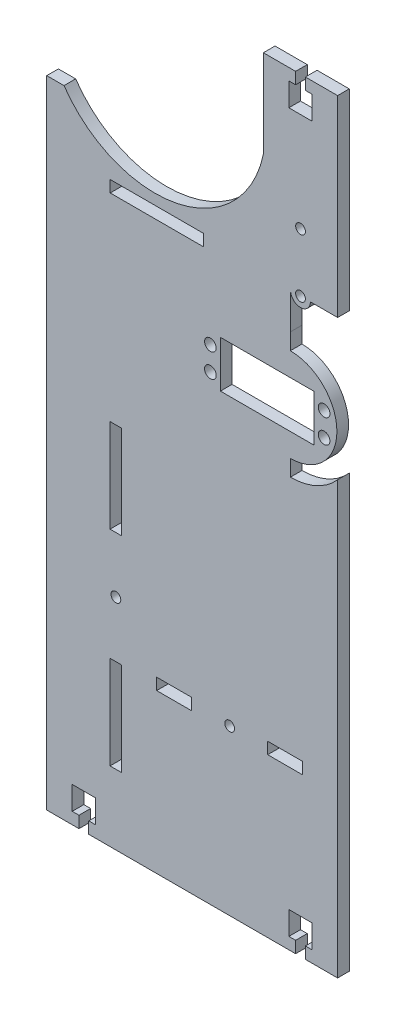
from build123d import *

# Parameters (mm, degrees)
SKETCH1_W           = 31.86
SKETCH1_H           = 328
BOSS_EXTRUDE1_DEPTH = 5
SKETCH2_R           = 2.1
CUT_EXTRUDE1_DEPTH  = 10
CUT_EXTRUDE2_DEPTH  = 10
BOSS_EXTRUDE2_DEPTH = 5
SKETCH7_W           = 4.2
SKETCH7_H           = 5
SKETCH7_R           = 2.099999245
CUT_EXTRUDE3_DEPTH  = 5
SKETCH8_R           = 2.499996422
SKETCH8_R_2         = 2.499996502
SKETCH8_R_3         = 2.5
SKETCH8_W           = 40.200355047
SKETCH8_H           = 20
CUT_EXTRUDE4_DEPTH  = 10
CUT_EXTRUDE5_DEPTH  = 10
CUT_EXTRUDE6_DEPTH  = 10
SKETCH12_R          = 2.100000755
SKETCH12_R_2        = 2.1
SKETCH12_W          = 15.000005391
SKETCH12_H          = 5
SKETCH12_W_2        = 5
SKETCH12_H_2        = 40
CUT_EXTRUDE7_DEPTH  = 5
SKETCH15_W          = 40
SKETCH15_H          = 5
CUT_EXTRUDE8_DEPTH  = 5


with BuildPart() as part:
    # Sketch1 → Boss-Extrude1 (new body)
    with BuildSketch(Plane.XY):
        Rectangle(SKETCH1_W, SKETCH1_H)
    extrude(amount=BOSS_EXTRUDE1_DEPTH)

    # Sketch2 → Cut-Extrude1 (cut)
    with BuildSketch(Plane.XY.offset(5)):
        with Locations((0, 81.5)):
            Circle(SKETCH2_R)
    extrude(amount=-CUT_EXTRUDE1_DEPTH, mode=Mode.SUBTRACT)

    # Sketch3 → Cut-Extrude2 (cut)
    with BuildSketch(Plane.XY.offset(5)):
        Polygon((2.1, 164), (2.1, 159), (5, 159), (5, 149), (-5, 149), (-5, 159), (-2.1, 159), (-2.1, 164), align=None)
        Polygon((-2.1, -164), (-2.1, -159), (-5, -159), (-5, -149), (5, -149), (5, -159), (2.1, -159), (2.1, -164), align=None)
    extrude(amount=-CUT_EXTRUDE2_DEPTH, mode=Mode.SUBTRACT)

    # Sketch4 → Boss-Extrude2 (add)
    with BuildSketch(Plane(origin=(0, 0, 0), x_dir=(-1, 0, 0), z_dir=(0, 0, -1))):
        with BuildLine():
            Line((15.93, -164), (108.913444487, -164))
            Line((108.913444487, -164), (108.913444487, 109))
            Line((108.913444487, 109), (101.503490547, 109))
            ThreePointArc((101.503490547, 109), (62.423444487, 88.5), (23.343398428, 109))
            ThreePointArc((23.343398428, 109), (18.773737927, 117.266257257), (15.93, 126.273252357))
            Line((15.93, 126.273252357), (15.93, 109))
            Line((15.93, 109), (15.93, -164))
        make_face()
    extrude(amount=-BOSS_EXTRUDE2_DEPTH)

    # Sketch7 → Cut-Extrude3 (cut)
    with BuildSketch(Plane.XY.offset(5)):
        Polygon((-95.083444487, -159), (-90.883444487, -159), (-87.983444487, -159), (-87.983444487, -149), (-97.983444487, -149), (-97.983444487, -159), align=None)
        with Locations((-92.983444487, -161.5)):
            Rectangle(SKETCH7_W, SKETCH7_H)
        with Locations((0.021526005, 106.5)):
            Circle(SKETCH7_R)
    extrude(amount=-CUT_EXTRUDE3_DEPTH, mode=Mode.SUBTRACT)

    # Sketch8 → Cut-Extrude4 (cut)
    with BuildSketch(Plane.XY.offset(5)):
        with Locations((-38.679067758, 44.08)):
            Circle(SKETCH8_R)
        with Locations((-38.679067758, 33.92)):
            Circle(SKETCH8_R_2)
        with Locations((10.13, 44.08)):
            Circle(SKETCH8_R_3)
        with Locations((10.13, 33.92)):
            Circle(SKETCH8_R_3)
        with Locations((-14.269822477, 39)):
            Rectangle(SKETCH8_W, SKETCH8_H)
    extrude(amount=-CUT_EXTRUDE4_DEPTH, mode=Mode.SUBTRACT)

    # Sketch9 → Cut-Extrude5 (cut)
    with BuildSketch(Plane(origin=(0, 0, 0), x_dir=(-1, 0, 0), z_dir=(0, 0, -1))):
        with BuildLine():
            Line((4.37, 12), (4.37, 19))
            ThreePointArc((4.37, 19), (-15.63, 39), (4.37, 59))
            Line((4.37, 59), (4.37, 66))
            ThreePointArc((4.37, 66), (-22.63, 39), (4.37, 12))
        make_face()
    extrude(amount=-CUT_EXTRUDE5_DEPTH, mode=Mode.SUBTRACT)

    # Sketch10 → Cut-Extrude6 (cut)
    with BuildSketch(Plane(origin=(0, 0, 0), x_dir=(-1, 0, 0), z_dir=(0, 0, -1))):
        with BuildLine():
            Line((-15.93, 66), (-15.93, 56.801966184))
            ThreePointArc((-15.93, 56.801966184), (-6.773314432, 63.593221495), (4.37, 66))
            Line((4.37, 66), (4.25, 81.5))
            ThreePointArc((4.25, 81.5), (0, 77.25), (-4.25, 81.5))
            Line((-4.25, 81.5), (-15.93, 81.5))
            Line((-15.93, 81.5), (-15.93, 66))
        make_face()
    extrude(amount=-CUT_EXTRUDE6_DEPTH, mode=Mode.SUBTRACT)

    # Sketch12 → Cut-Extrude7 (cut)
    with BuildSketch(Plane(origin=(0, 0, 0), x_dir=(-1, 0, 0), z_dir=(0, 0, -1))):
        with Locations((30.403186809, -93.5)):
            Circle(SKETCH12_R)
        with Locations((79.236368236, -70)):
            Circle(SKETCH12_R_2)
        with Locations((54.236365541, -93.5)):
            Rectangle(SKETCH12_W, SKETCH12_H)
        with Locations((6.570008077, -93.5)):
            Rectangle(SKETCH12_W, SKETCH12_H)
        with Locations((79.236368236, -114)):
            Rectangle(SKETCH12_W_2, SKETCH12_H_2)
        with Locations((79.236368236, -26)):
            Rectangle(SKETCH12_W_2, SKETCH12_H_2)
    extrude(amount=-CUT_EXTRUDE7_DEPTH, mode=Mode.SUBTRACT)

    # Sketch15 → Cut-Extrude8 (cut)
    with BuildSketch(Plane.XY.offset(5)):
        with Locations((-61.674975637, 81.5)):
            Rectangle(SKETCH15_W, SKETCH15_H)
    extrude(amount=-CUT_EXTRUDE8_DEPTH, mode=Mode.SUBTRACT)


solid = part.part
